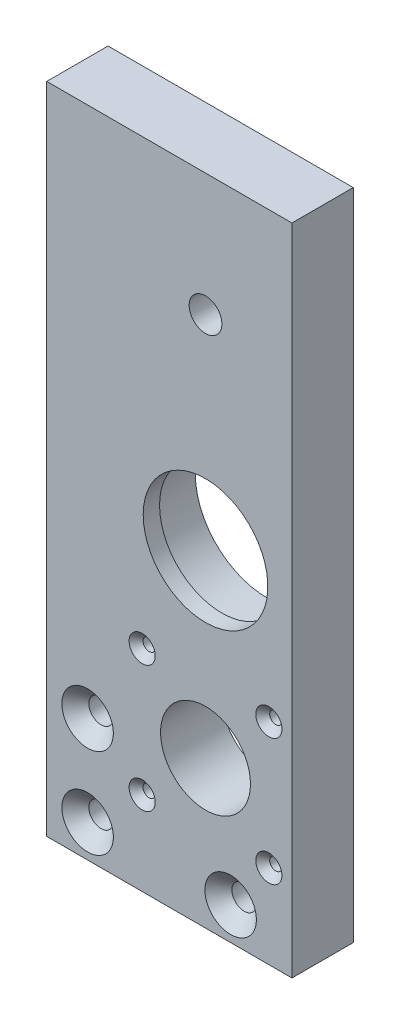
from build123d import *

# Parameters (mm, degrees)
SKIZZE1_W                        = 65
SKIZZE1_H                        = 160
AUFSATZ_LINEAR_AUSTRAGEN1_DEPTH  = 15
SKIZZE2_R                        = 17.5
SCHNITT_LINEAR_AUSTRAGEN1_DEPTH  = 11
SKIZZE4_R                        = 15.25
SCHNITT_LINEAR_AUSTRAGEN3_DEPTH  = 10
SKIZZE5_R                        = 11
SCHNITT_LINEAR_AUSTRAGEN4_DEPTH  = 20
SKIZZE7_R                        = 3
SCHNITT_LINEAR_AUSTRAGEN6_DEPTH  = 17
FASE1_SIZE                       = 3.3
SKIZZE10_R                       = 3
SCHNITT_LINEAR_AUSTRAGEN9_DEPTH  = 29
FASE2_SIZE                       = 3.3
SKIZZE11_R                       = 1.5
SCHNITT_LINEAR_AUSTRAGEN10_DEPTH = 44
FASE3_SIZE                       = 1.7
SKIZZE13_R                       = 4
SCHNITT_LINEAR_AUSTRAGEN12_DEPTH = 35
SKIZZE14_W                       = 15
SKIZZE14_H                       = 160
SCHNITT_LINEAR_AUSTRAGEN13_DEPTH = 5


with BuildPart() as part:
    # Skizze1 → Aufsatz-Linear austragen1 (new body)
    with BuildSketch(Plane.XY):
        with Locations((32.5, 80)):
            Rectangle(SKIZZE1_W, SKIZZE1_H)
    extrude(amount=AUFSATZ_LINEAR_AUSTRAGEN1_DEPTH)

    # Skizze2 → Schnitt-Linear austragen1 (cut)
    with BuildSketch(Plane(origin=(0, 0, 0), x_dir=(-1, 0, 0), z_dir=(0, 0, -1))):
        with Locations((-43.85, 80)):
            Circle(SKIZZE2_R)
    extrude(amount=-SCHNITT_LINEAR_AUSTRAGEN1_DEPTH, mode=Mode.SUBTRACT)

    # Skizze4 → Schnitt-Linear austragen3 (cut)
    with BuildSketch(Plane(origin=(0, 0, 11), x_dir=(-1, 0, 0), z_dir=(0, 0, -1))):
        with Locations((-43.85, 80)):
            Circle(SKIZZE4_R)
    extrude(amount=-SCHNITT_LINEAR_AUSTRAGEN3_DEPTH, mode=Mode.SUBTRACT)

    # Skizze5 → Schnitt-Linear austragen4 (cut)
    with BuildSketch(Plane.XY.offset(15)):
        with Locations((43.85, 36)):
            Circle(SKIZZE5_R)
    extrude(amount=-SCHNITT_LINEAR_AUSTRAGEN4_DEPTH, mode=Mode.SUBTRACT)

    # Skizze7 → Schnitt-Linear austragen6 (cut)
    with BuildSketch(Plane.XY.offset(15)):
        with Locations((15, 8)):
            Circle(SKIZZE7_R)
        with Locations((50, 8)):
            Circle(SKIZZE7_R)
    extrude(amount=-SCHNITT_LINEAR_AUSTRAGEN6_DEPTH, mode=Mode.SUBTRACT)

    # Fase1
    fase1_edges = [part.edges().sort_by_distance(p)[0] for p in [
        (12, 8, 15),
        (47, 8, 15),
    ]]
    chamfer(fase1_edges, length=FASE1_SIZE)

    # Skizze10 → Schnitt-Linear austragen9 (cut)
    with BuildSketch(Plane.XY.offset(15)):
        with Locations((15, 30)):
            Circle(SKIZZE10_R)
    extrude(amount=-SCHNITT_LINEAR_AUSTRAGEN9_DEPTH, mode=Mode.SUBTRACT)

    # Fase2
    fase2_edges = [part.edges().sort_by_distance(p)[0] for p in [
        (12, 30, 15),
    ]]
    chamfer(fase2_edges, length=FASE2_SIZE)

    # Skizze11 → Schnitt-Linear austragen10 (cut)
    with BuildSketch(Plane.XY.offset(15)):
        with Locations((59.35, 51.5)):
            Circle(SKIZZE11_R)
        with Locations((59.35, 20.5)):
            Circle(SKIZZE11_R)
        with Locations((28.35, 51.5)):
            Circle(SKIZZE11_R)
        with Locations((28.35, 20.5)):
            Circle(SKIZZE11_R)
    extrude(amount=-SCHNITT_LINEAR_AUSTRAGEN10_DEPTH, mode=Mode.SUBTRACT)

    # Fase3
    fase3_edges = [part.edges().sort_by_distance(p)[0] for p in [
        (57.85, 51.5, 15),
        (57.85, 20.5, 15),
        (26.85, 51.5, 15),
        (26.85, 20.5, 15),
    ]]
    chamfer(fase3_edges, length=FASE3_SIZE)

    # Skizze13 → Schnitt-Linear austragen12 (cut)
    with BuildSketch(Plane.XY.offset(15)):
        with Locations((43.85, 130)):
            Circle(SKIZZE13_R)
    extrude(amount=-SCHNITT_LINEAR_AUSTRAGEN12_DEPTH, mode=Mode.SUBTRACT)

    # Skizze14 → Schnitt-Linear austragen13 (cut)
    with BuildSketch(Plane.ZY):
        with Locations((7.5, 80)):
            Rectangle(SKIZZE14_W, SKIZZE14_H)
    extrude(amount=-SCHNITT_LINEAR_AUSTRAGEN13_DEPTH, mode=Mode.SUBTRACT)


solid = part.part
